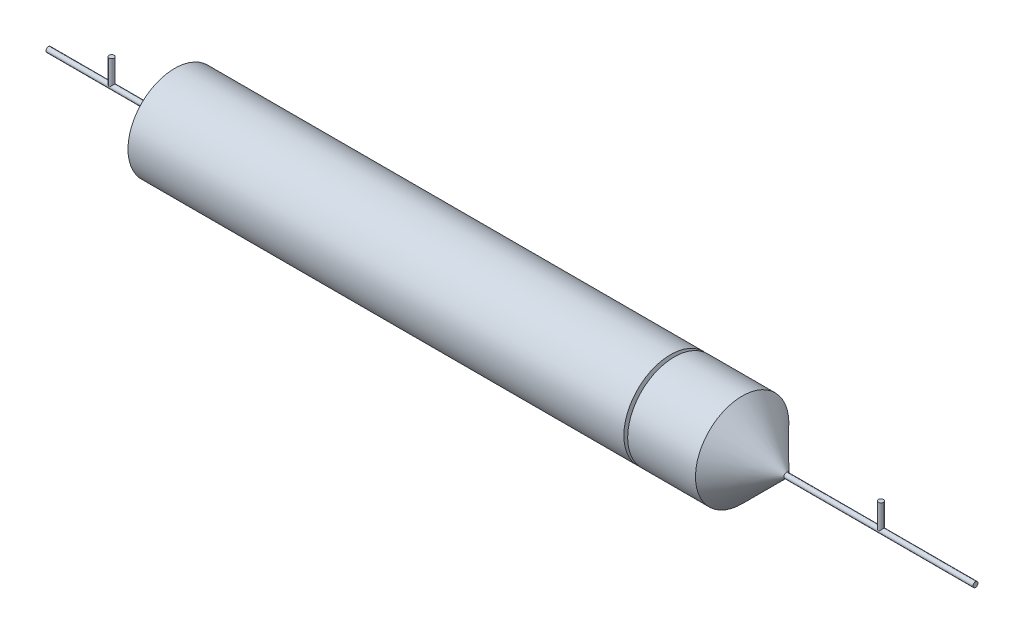
from build123d import *

# Parameters (mm, degrees)
SKETCH2_R           = 2
BOSS_EXTRUDE1_DEPTH = 20
SKETCH5_R           = 0.5
CUT_EXTRUDE1_DEPTH  = 10


with BuildPart() as part:
    # Sketch1 → Revolve1 (revolve)
    with BuildSketch(Plane.XY):
        Polygon((-225, 2), (-225, 37), (225, 37), (260, 2), (410, 2), (410, 0), (-125, 0), (-325, 0), (-325, 2), align=None)
    revolve(axis=Axis((-125, 0, 0), (1, 0, 0)))

    # Sketch2 → Boss-Extrude1 (add)
    with BuildSketch(Plane(origin=(0, 0, 0), x_dir=(1, 0, 0), z_dir=(0, 1, 0))):
        with Locations((-275, 0)):
            Circle(SKETCH2_R)
        with Locations((335, 0)):
            Circle(SKETCH2_R)
    extrude(amount=BOSS_EXTRUDE1_DEPTH)


with BuildPart() as body_2:
    # Sketch4 → Revolve2 (revolve)
    with BuildSketch(Plane(origin=(0, 0, 0), x_dir=(1, 0, 0), z_dir=(0, 1, 0))):
        Polygon((181.031907012, 0), (181.031907012, 10), (171.204710687, 37), (168.204710687, 37), (178.031907012, 10), (178.031907012, 0), align=None)
    revolve(axis=Axis((178.031907012, 0, 0), (1, 0, 0)))

    # Sketch5 → Cut-Extrude1 (cut)
    with BuildSketch(Plane.ZY.offset(-178.031907012)):
        Circle(SKETCH5_R)
    extrude(amount=-CUT_EXTRUDE1_DEPTH, mode=Mode.SUBTRACT)


with BuildPart() as part_1:
    add(part.part)

    # Combine1: cut body 2
    add(body_2.part, mode=Mode.SUBTRACT)


solid = part_1.part
